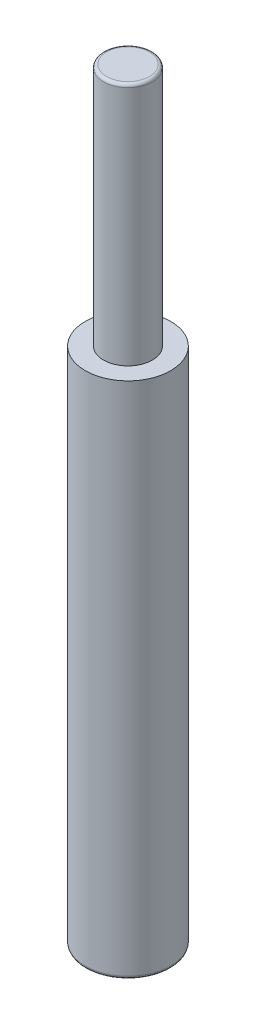
from build123d import *

# Parameters (mm, degrees)
SKETCH1_R           = 4
BOSS_EXTRUDE1_DEPTH = 40
SKETCH1_3_R         = 7
BOSS_EXTRUDE2_DEPTH = 85
FILLET1_R           = 0.5


with BuildPart() as part:
    # Sketch1 → Boss-Extrude1 (new body)
    with BuildSketch(Plane(origin=(0, 0, 0), x_dir=(1, 0, 0), z_dir=(0, 1, 0))):
        Circle(SKETCH1_R)
    extrude(amount=BOSS_EXTRUDE1_DEPTH)

    # Sketch1_3 → Boss-Extrude2 (add)
    with BuildSketch(Plane(origin=(0, 0, 0), x_dir=(1, 0, 0), z_dir=(0, 1, 0))):
        Circle(SKETCH1_3_R)
    extrude(amount=-BOSS_EXTRUDE2_DEPTH)

    # Fillet1
    fillet1_edges = [part.edges().sort_by_distance(p)[0] for p in [
        (-7, -85, 0),
        (-4, 40, 0),
    ]]
    fillet(fillet1_edges, radius=FILLET1_R)


solid = part.part
